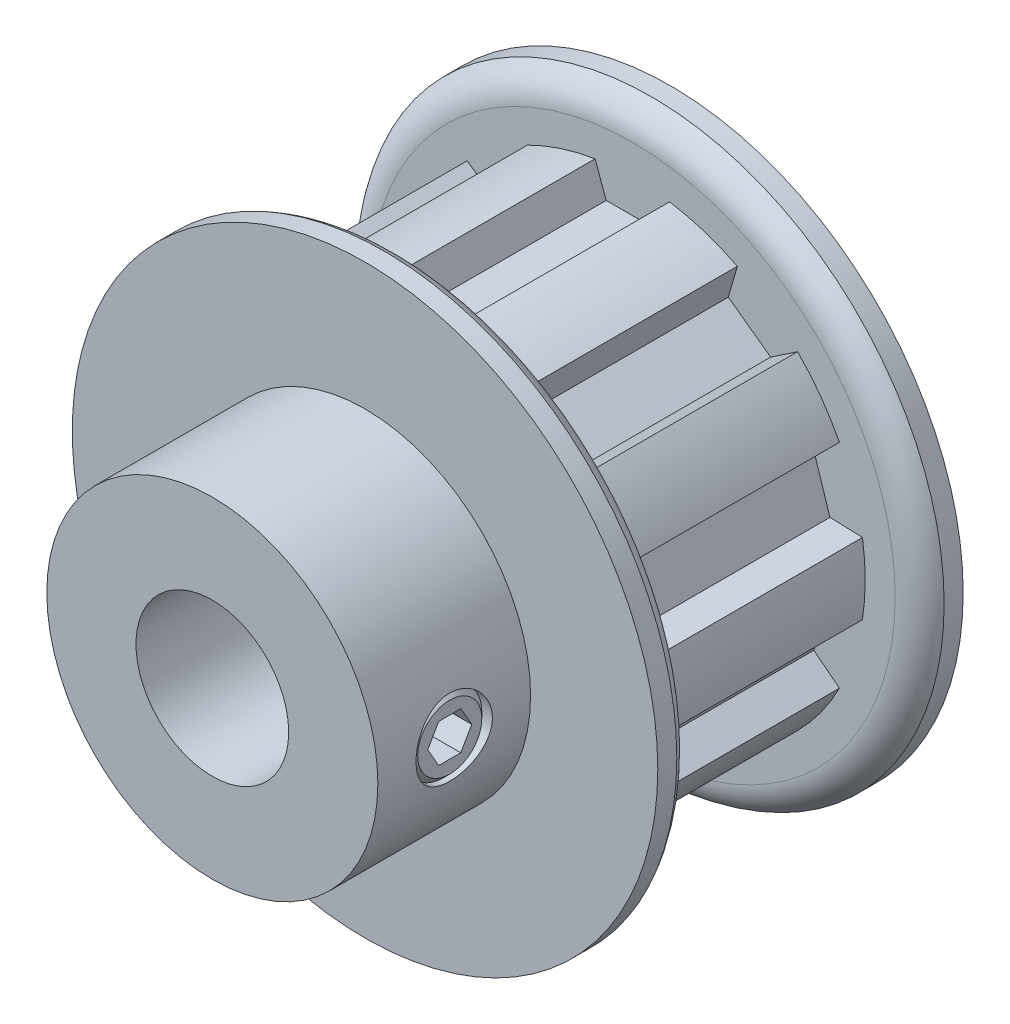
from build123d import *

# Parameters (mm, degrees)
CUT_EXTRUDE1_START = 2.3876
CUT_EXTRUDE1_DEPTH = 14.3002
CIRPATTERN1_COUNT  = 10
SKETCH4_R          = 2.38125
CUT_EXTRUDE2_DEPTH = 30.51572079
CUT_EXTRUDE3_DEPTH = 1.7859375


with BuildPart() as part:
    # Sketch2 → Revolve1 (revolve)
    with BuildSketch(Plane(origin=(0, 0, 0), x_dir=(0, 0, -1), z_dir=(1, 0, 0)), mode=Mode.PRIVATE) as revolve1_sk:
        with BuildLine():
            Line((-14.2875, 4.7625), (14.2875, 4.7625))
            Line((14.2875, 4.7625), (14.2875, 18.2626))
            Line((14.2875, 18.2626), (13.10005, 18.2626))
            ThreePointArc((13.10005, 18.2626), (12.234576959, 17.500999922), (11.9126, 16.394017943))
            Line((11.9126, 16.394017943), (11.9126, 14.525435887))
            Line((11.9126, 14.525435887), (-2.3876, 14.525435887))
            Line((-2.3876, 14.525435887), (-2.3876, 16.394017943))
            ThreePointArc((-2.3876, 16.394017943), (-2.709576959, 17.500999922), (-3.57505, 18.2626))
            Line((-3.57505, 18.2626), (-4.7625, 18.2626))
            Line((-4.7625, 18.2626), (-4.7625, 10.3251))
            Line((-4.7625, 10.3251), (-14.2875, 10.3251))
            Line((-14.2875, 10.3251), (-14.2875, 4.7625))
        make_face()
    revolve(revolve1_sk.sketch.rotate(Axis((0, 0, 14.2875), (0, 0, -1)), 90), axis=Axis((0, 0, 14.2875), (0, 0, -1)))

    # Sketch3 → Cut-Extrude1 (cut)
    with BuildSketch(Plane.XY.offset(CUT_EXTRUDE1_START)):
        with BuildLine():
            Line((-1.630736704, 12.4333), (1.630736704, 12.4333))
            Line((1.630736704, 12.4333), (2.3241, 14.3383))
            ThreePointArc((2.3241, 14.3383), (0, 14.525435887), (-2.3241, 14.3383))
            Line((-2.3241, 14.3383), (-1.630736704, 12.4333))
        make_face()
    cut_extrude1 = extrude(amount=-CUT_EXTRUDE1_DEPTH, mode=Mode.SUBTRACT)

    # CirPattern1: Cut-Extrude1 ×10 about axis
    cirpattern1_axis = Axis((0, 0, 0), (0, 0, 1))
    for i in range(1, CIRPATTERN1_COUNT):
        add(cut_extrude1.rotate(cirpattern1_axis, i * 360 / CIRPATTERN1_COUNT), mode=Mode.SUBTRACT)

    # Sketch4 → Cut-Extrude2 (cut, through all)
    with BuildSketch(Plane(origin=(0, 0, 0), x_dir=(0, -1, 0), z_dir=(1, 0, 0))):
        with Locations(Location((0, -9.525, 0), (0, 0, 270))):
            Circle(SKETCH4_R)
    extrude(amount=CUT_EXTRUDE2_DEPTH, mode=Mode.SUBTRACT)

    # Sketch5 → Revolve2 (revolve)
    with BuildSketch(Plane.XY.offset(9.525)):
        Polygon((4.7625, -2.00025), (4.7625, 0), (10.046757609, 0), (10.046757609, -2.00025), (9.665757609, -2.38125), (5.1435, -2.38125), align=None)
    revolve(axis=Axis((4.7625, 0, 9.525), (1, 0, 0)))

    # Sketch6 → Cut-Extrude3 (cut)
    with BuildSketch(Plane(origin=(10.046757609, 5.384140679, 0), x_dir=(0, -1, 0), z_dir=(-1, 0, 0))):
        Polygon((5.384140679, 10.899815329), (4.193515679, 10.212407664), (4.193515679, 8.837592336), (5.384140679, 8.150184671), (6.574765679, 8.837592336), (6.574765679, 10.212407664), align=None)
    extrude(amount=CUT_EXTRUDE3_DEPTH, mode=Mode.SUBTRACT)


solid = part.part
